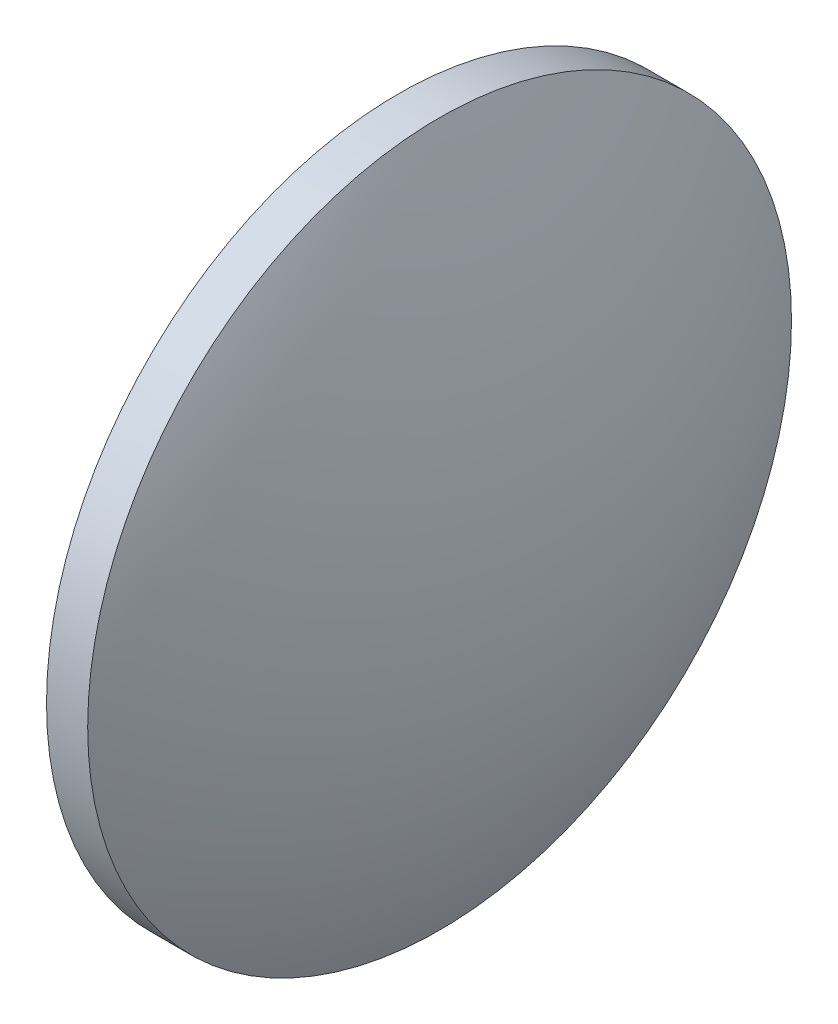
from build123d import *

# Parameters (mm, degrees)
SKETCH1_R           = 21.37
BOSS_EXTRUDE1_DEPTH = 2.5
DOME1_FACE_RADIUS   = 21.37
DOME1_HEIGHT        = 5


with BuildPart() as part:
    # Sketch1 → Boss-Extrude1 (new body)
    with BuildSketch(Plane(origin=(0, 0, 0), x_dir=(0, 0, -1), z_dir=(1, 0, 0))):
        Circle(SKETCH1_R)
    extrude(amount=BOSS_EXTRUDE1_DEPTH)

    # Dome1: a dome of height H over a round flat face of radius A is a cap of a sphere of radius (A * A + H * H) / (2 * H)
    dome1_r = (DOME1_FACE_RADIUS * DOME1_FACE_RADIUS + DOME1_HEIGHT * DOME1_HEIGHT) / (2 * DOME1_HEIGHT)
    dome1_base = Plane((2.5, 0, 0), z_dir=(1, 0, 0))
    with Locations(dome1_base.offset(DOME1_HEIGHT - dome1_r)):
        dome1_ball = Sphere(dome1_r, mode=Mode.PRIVATE)
    add(split(dome1_ball, bisect_by=dome1_base, keep=Keep.TOP, mode=Mode.PRIVATE))


solid = part.part
